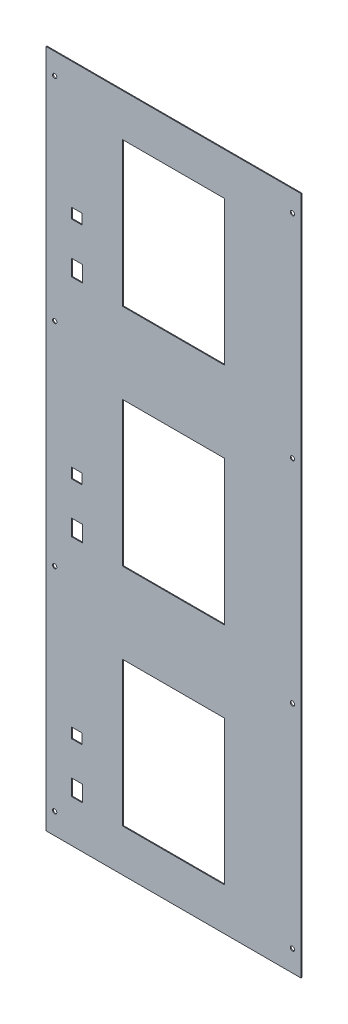
from build123d import *

# Parameters (mm, degrees)
SKETCH1_W           = 300
SKETCH1_H           = 800
SKETCH1_W_2         = 120
SKETCH1_H_2         = 170
BOSS_EXTRUDE1_DEPTH = 1
SKETCH4_R           = 2.5
CUT_EXTRUDE1_DEPTH  = 10
SKETCH5_W           = 12.6
SKETCH5_H           = 19
SKETCH5_W_2         = 12
SKETCH5_H_2         = 12
CUT_EXTRUDE2_DEPTH  = 10


with BuildPart() as part:
    # Sketch1 → Boss-Extrude1 (new body)
    with BuildSketch(Plane.XY):
        Rectangle(SKETCH1_W, SKETCH1_H)
        Rectangle(SKETCH1_W_2, SKETCH1_H_2, mode=Mode.SUBTRACT)
        with Locations((0, 265)):
            Rectangle(SKETCH1_W_2, SKETCH1_H_2, mode=Mode.SUBTRACT)
        with Locations((0, -265)):
            Rectangle(SKETCH1_W_2, SKETCH1_H_2, mode=Mode.SUBTRACT)
    extrude(amount=BOSS_EXTRUDE1_DEPTH)

    # Sketch4 → Cut-Extrude1 (cut)
    with BuildSketch(Plane.XY.offset(1)):
        with Locations((140, 375)):
            Circle(SKETCH4_R)
        with Locations((-140, 375)):
            Circle(SKETCH4_R)
        with Locations((-140, 125)):
            Circle(SKETCH4_R)
        with Locations((-140, -125)):
            Circle(SKETCH4_R)
        with Locations((-140, -375)):
            Circle(SKETCH4_R)
        with Locations((140, 125)):
            Circle(SKETCH4_R)
        with Locations((140, -125)):
            Circle(SKETCH4_R)
        with Locations((140, -375)):
            Circle(SKETCH4_R)
    extrude(amount=-CUT_EXTRUDE1_DEPTH, mode=Mode.SUBTRACT)

    # Sketch5 → Cut-Extrude2 (cut)
    with BuildSketch(Plane.XY.offset(1)):
        with Locations((-113.7, 189.5)):
            Rectangle(SKETCH5_W, SKETCH5_H)
        with Locations((-113.7, -75.5)):
            Rectangle(SKETCH5_W, SKETCH5_H)
        with Locations((-113.7, -340.5)):
            Rectangle(SKETCH5_W, SKETCH5_H)
        with Locations((-114, -20)):
            Rectangle(SKETCH5_W_2, SKETCH5_H_2)
        with Locations((-114, 245)):
            Rectangle(SKETCH5_W_2, SKETCH5_H_2)
        with Locations((-114, -285)):
            Rectangle(SKETCH5_W_2, SKETCH5_H_2)
    extrude(amount=-CUT_EXTRUDE2_DEPTH, mode=Mode.SUBTRACT)


solid = part.part
